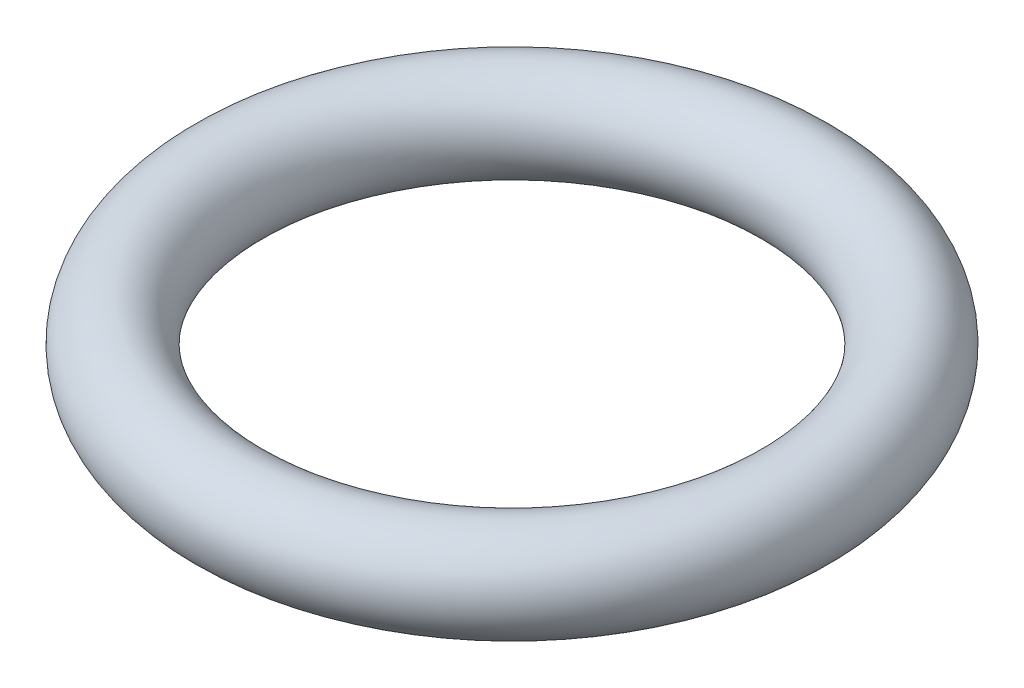
from build123d import *

# Parameters (mm, degrees)
SKETCH1_R = 25.4


with BuildPart() as part:
    # Sketch1 → Revolve1 (revolve)
    with BuildSketch(Plane.XY):
        with Locations((152.4, 0)):
            Circle(SKETCH1_R)
    revolve(axis=Axis((0, 0, 0), (0, 1, 0)))


solid = part.part
